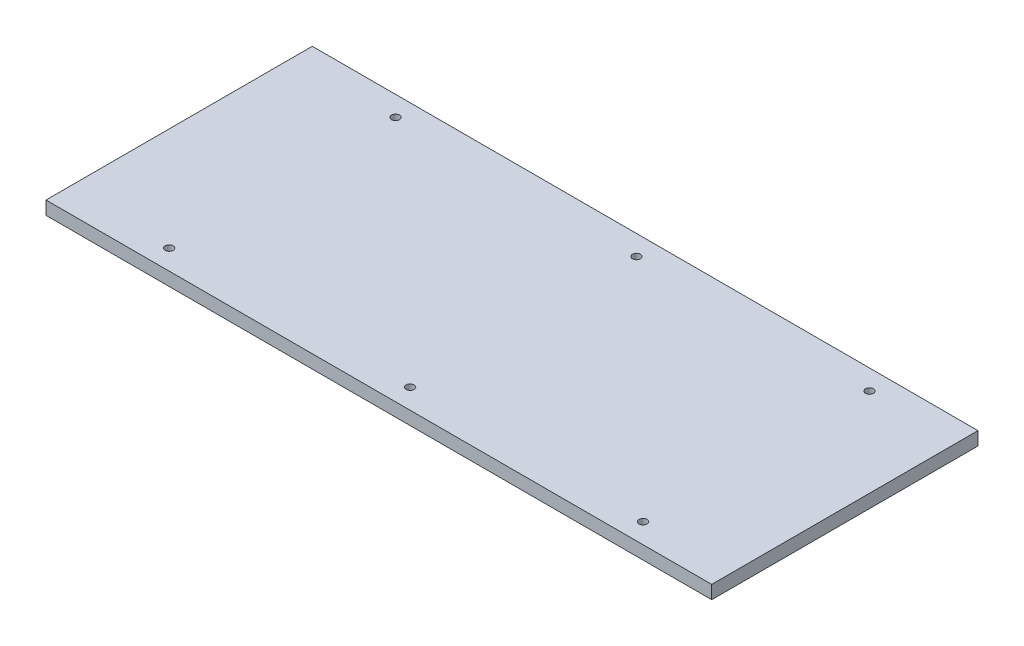
from build123d import *

# Parameters (mm, degrees)
SKETCH1_W           = 500
SKETCH1_H           = 200
SKETCH1_R           = 3
BOSS_EXTRUDE1_DEPTH = 10


with BuildPart() as part:
    # Sketch1 → Boss-Extrude1 (new body)
    with BuildSketch(Plane(origin=(0, 0, 0), x_dir=(1, 0, 0), z_dir=(0, 1, 0))):
        Rectangle(SKETCH1_W, SKETCH1_H)
        with Locations((8.493329942, 85)):
            Circle(SKETCH1_R, mode=Mode.SUBTRACT)
        with Locations((8.493329942, -85)):
            Circle(SKETCH1_R, mode=Mode.SUBTRACT)
        with Locations((-172.506670058, 85)):
            Circle(SKETCH1_R, mode=Mode.SUBTRACT)
        with Locations((-172.506670058, -85)):
            Circle(SKETCH1_R, mode=Mode.SUBTRACT)
        with Locations((183.493329942, -85)):
            Circle(SKETCH1_R, mode=Mode.SUBTRACT)
        with Locations((183.493329942, 85)):
            Circle(SKETCH1_R, mode=Mode.SUBTRACT)
    extrude(amount=BOSS_EXTRUDE1_DEPTH)


solid = part.part
